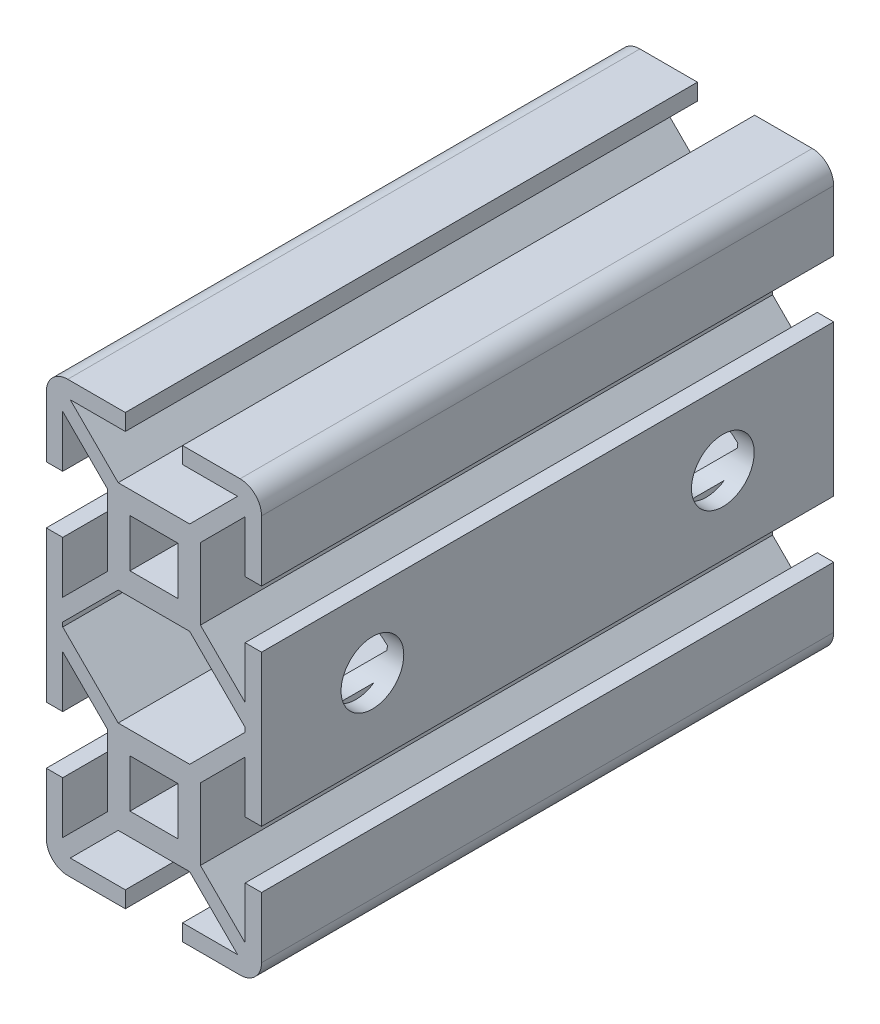
from build123d import *

# Parameters (mm, degrees)
CROQUIS1_W              = 6.7
CROQUIS1_H              = 6.7
SALIENTE_EXTRUIR1_DEPTH = 80
CROQUIS2_R              = 4.38396011
CORTAR_EXTRUIR1_DEPTH   = 34


with BuildPart() as part:
    # Croquis1 → Saliente-Extruir1 (new body)
    with BuildSketch(Plane.XY):
        with BuildLine():
            Line((-12.05, -30.05), (-4, -30.05))
            Line((-4, -30.05), (-4, -27.75))
            Line((-4, -27.75), (-11.7, -27.75))
            Line((-11.7, -27.75), (-5, -21.05))
            Line((-5, -21.05), (5, -21.05))
            Line((5, -21.05), (11.7, -27.75))
            Line((11.7, -27.75), (4, -27.75))
            Line((4, -27.75), (4, -30.05))
            Line((4, -30.05), (12.05, -30.05))
            ThreePointArc((12.05, -30.05), (14.171320344, -29.171320344), (15.05, -27.05))
            Line((15.05, -27.05), (15.05, -18.55))
            Line((15.05, -18.55), (12.75, -18.55))
            Line((12.75, -18.55), (12.75, -25.8))
            Line((12.75, -25.8), (6.5, -19.55))
            Line((6.5, -19.55), (6.5, -9.55))
            Line((6.5, -9.55), (12.75, -3.3))
            Line((12.75, -3.3), (12.75, -10.55))
            Line((12.75, -10.55), (15.05, -10.55))
            Line((15.05, -10.55), (15.05, 10.55))
            Line((15.05, 10.55), (12.75, 10.55))
            Line((12.75, 10.55), (12.75, 3.3))
            Line((12.75, 3.3), (6.5, 9.55))
            Line((6.5, 9.55), (6.5, 19.55))
            Line((6.5, 19.55), (12.75, 25.8))
            Line((12.75, 25.8), (12.75, 18.55))
            Line((12.75, 18.55), (15.05, 18.55))
            Line((15.05, 18.55), (15.05, 27.05))
            ThreePointArc((15.05, 27.05), (14.171320344, 29.171320344), (12.05, 30.05))
            Line((12.05, 30.05), (4, 30.05))
            Line((4, 30.05), (4, 27.75))
            Line((4, 27.75), (11.7, 27.75))
            Line((11.7, 27.75), (5, 21.05))
            Line((5, 21.05), (-5, 21.05))
            Line((-5, 21.05), (-11.7, 27.75))
            Line((-11.7, 27.75), (-4, 27.75))
            Line((-4, 27.75), (-4, 30.05))
            Line((-4, 30.05), (-12.05, 30.05))
            ThreePointArc((-12.05, 30.05), (-14.171320344, 29.171320344), (-15.05, 27.05))
            Line((-15.05, 27.05), (-15.05, 18.55))
            Line((-15.05, 18.55), (-12.75, 18.55))
            Line((-12.75, 18.55), (-12.75, 25.8))
            Line((-12.75, 25.8), (-6.5, 19.55))
            Line((-6.5, 19.55), (-6.5, 9.55))
            Line((-6.5, 9.55), (-12.75, 3.3))
            Line((-12.75, 3.3), (-12.75, 10.55))
            Line((-12.75, 10.55), (-15.05, 10.55))
            Line((-15.05, 10.55), (-15.05, -10.55))
            Line((-15.05, -10.55), (-12.75, -10.55))
            Line((-12.75, -10.55), (-12.75, -3.3))
            Line((-12.75, -3.3), (-6.5, -9.55))
            Line((-6.5, -9.55), (-6.5, -19.55))
            Line((-6.5, -19.55), (-12.75, -25.8))
            Line((-12.75, -25.8), (-12.75, -18.55))
            Line((-12.75, -18.55), (-15.05, -18.55))
            Line((-15.05, -18.55), (-15.05, -27.05))
            ThreePointArc((-15.05, -27.05), (-14.171320344, -29.171320344), (-12.05, -30.05))
        make_face()
        Polygon((-5, 8.05), (5, 8.05), (11.7, 1.35), (12.75, 0.3), (12.75, -0.3), (11.7, -1.35), (5, -8.05), (-5, -8.05), (-11.7, -1.35), (-12.75, -0.3), (-12.75, 0.3), (-11.7, 1.35), align=None, mode=Mode.SUBTRACT)
        with Locations((0, 14.55)):
            Rectangle(CROQUIS1_W, CROQUIS1_H, mode=Mode.SUBTRACT)
        with Locations((0, -14.55)):
            Rectangle(CROQUIS1_W, CROQUIS1_H, mode=Mode.SUBTRACT)
    extrude(amount=SALIENTE_EXTRUIR1_DEPTH)

    # Croquis2 → Cortar-Extruir1 (cut)
    with BuildSketch(Plane(origin=(15.05, 0, 0), x_dir=(0, 0, -1), z_dir=(1, 0, 0))):
        with Locations((-64.5, 0.3)):
            Circle(CROQUIS2_R)
        with Locations((-15.5, 0.3)):
            Circle(CROQUIS2_R)
    extrude(amount=-CORTAR_EXTRUIR1_DEPTH, mode=Mode.SUBTRACT)


solid = part.part
